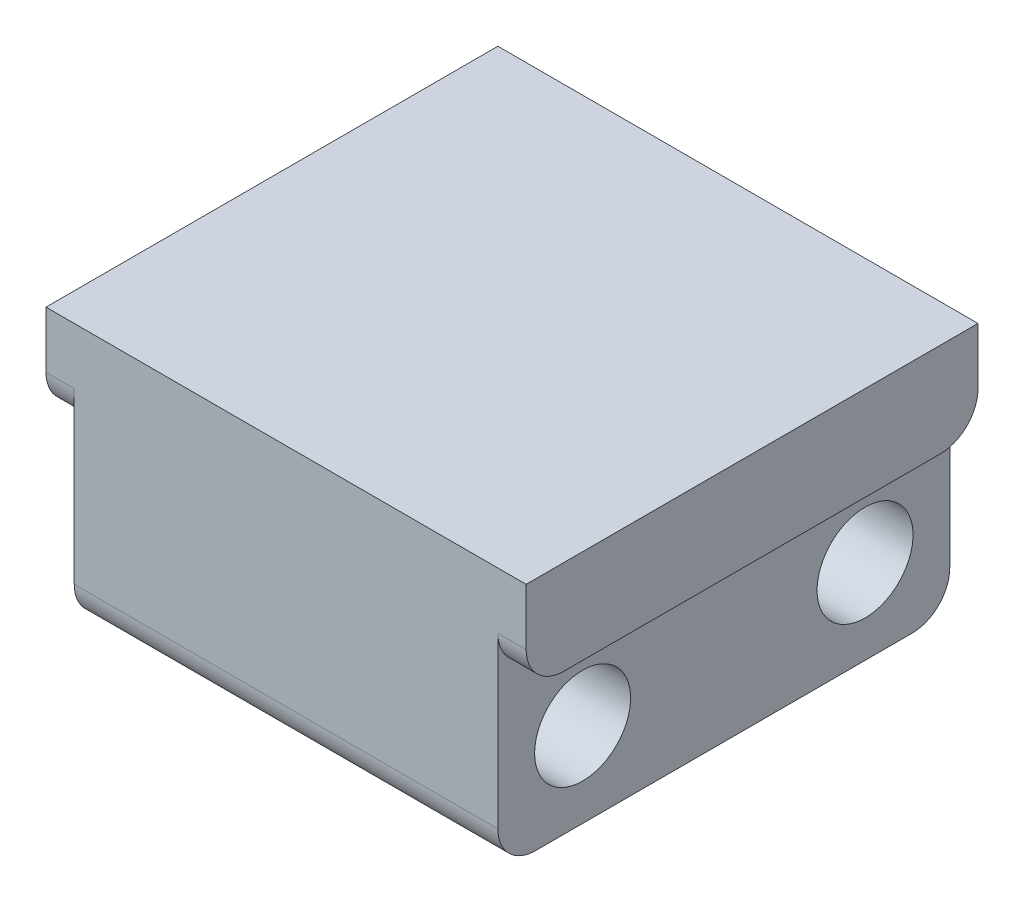
from build123d import *

# Parameters (mm, degrees)
MAIN_BODY_DEPTH            = 12
SKETCH2_R                  = 2.55
CLEARANCE_M3_INSERTS_DEPTH = 25
CONTOURING_R               = 2


with BuildPart() as part:
    # Sketch1 → Main Body (new body, symmetric)
    with BuildSketch(Plane.XY):
        Polygon((11.25, 0), (-11.25, 0), (-11.25, 9), (-12.75, 9), (-12.75, 14), (12.75, 14), (12.75, 9), (11.25, 9), align=None)
    extrude(amount=MAIN_BODY_DEPTH, both=True)

    # Sketch2 → Clearance - M3 Inserts (cut, through all)
    with BuildSketch(Plane.ZY.offset(11.25)):
        with Locations((-7.5, 4.5)):
            Circle(SKETCH2_R)
        with Locations((7.5, 4.5)):
            Circle(SKETCH2_R)
    extrude(amount=-CLEARANCE_M3_INSERTS_DEPTH, mode=Mode.SUBTRACT)

    # Contouring
    contouring_edges = [part.edges().sort_by_distance(p)[0] for p in [
        (12, 9, -12),
        (-12, 9, 12),
        (0, 0, 12),
        (12, 9, 12),
        (0, 0, -12),
        (-12, 9, -12),
    ]]
    fillet(contouring_edges, radius=CONTOURING_R)


solid = part.part
